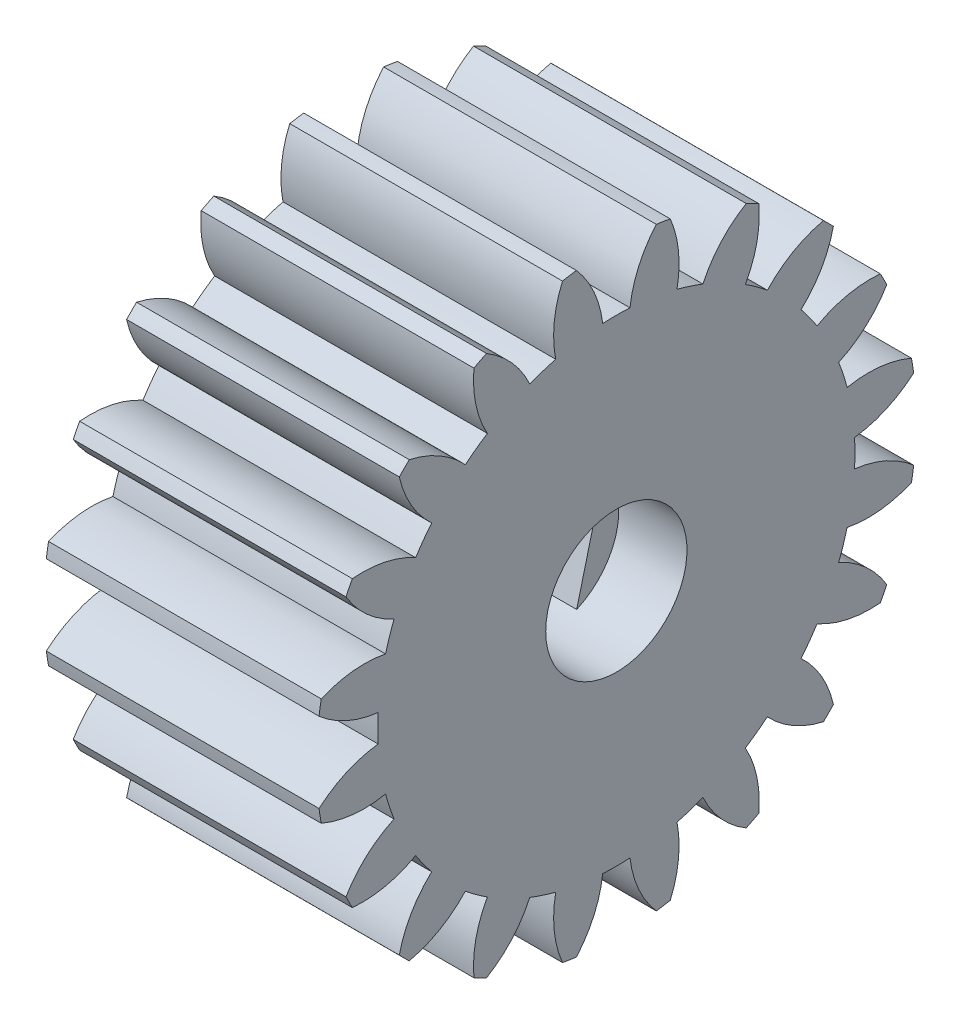
from build123d import *

# Parameters (mm, degrees)
SKETCH1_W           = 10
SKETCH1_H           = 11
CUT_EXTRUDE1_DEPTH  = 11
CUT_EXTRUDE2_DEPTH  = 11
CUT_EXTRUDE3_DEPTH  = 11
CUT_EXTRUDE4_DEPTH  = 11
CUT_EXTRUDE5_DEPTH  = 11
CUT_EXTRUDE6_DEPTH  = 11
CUT_EXTRUDE7_DEPTH  = 11
CUT_EXTRUDE8_DEPTH  = 11
CUT_EXTRUDE9_DEPTH  = 11
CUT_EXTRUDE10_DEPTH = 11
CUT_EXTRUDE11_DEPTH = 11
CUT_EXTRUDE12_DEPTH = 11
CUT_EXTRUDE13_DEPTH = 11
CUT_EXTRUDE14_DEPTH = 11
CUT_EXTRUDE15_DEPTH = 11
CUT_EXTRUDE16_DEPTH = 11
CUT_EXTRUDE17_DEPTH = 11
CUT_EXTRUDE18_DEPTH = 11
CUT_EXTRUDE19_DEPTH = 11
CUT_EXTRUDE20_DEPTH = 11
HOLE1_D             = 5.18
HOLE1_DEPTH         = 10
BOSS_EXTRUDE1_DEPTH = 7.5
BOSS_EXTRUDE2_DEPTH = 7.5


with BuildPart() as part:
    # Sketch1 → Revolve1 (revolve)
    with BuildSketch(Plane(origin=(0, 0, 0), x_dir=(-1, 0, 0), z_dir=(0, 0, -1))):
        with Locations((-5, 5.5)):
            Rectangle(SKETCH1_W, SKETCH1_H)
    revolve(axis=Axis((10, 0, 0), (-1, 0, 0)))

    # Sketch2 → Cut-Extrude1 (cut, through all)
    with BuildSketch(Plane.ZY):
        with BuildLine():
            ThreePointArc((10.821127601, -1.975651141), (9.66022001, -2.278635697), (8.461683425, -2.223716399))
            ThreePointArc((8.461683425, -2.223716399), (8.320793461, -2.703589684), (8.152713396, -3.174628369))
            ThreePointArc((8.152713396, -3.174628369), (9.154630615, -3.834679853), (9.915734733, -4.762163869))
            ThreePointArc((9.915734733, -4.762163869), (10.461621679, -3.399186938), (10.821127601, -1.975651141))
        make_face()
    extrude(amount=-CUT_EXTRUDE1_DEPTH, mode=Mode.SUBTRACT)

    # Sketch3 → Cut-Extrude2 (cut, through all)
    with BuildSketch(Plane.ZY):
        with BuildLine():
            ThreePointArc((9.680994141, -5.222868219), (8.483278035, -5.15228348), (7.360373002, -4.729683951))
            ThreePointArc((7.360373002, -4.729683951), (7.078089684, -5.142533172), (6.772677084, -5.538577987))
            ThreePointArc((6.772677084, -5.538577987), (7.521589858, -6.4759337), (7.958834566, -7.593217523))
            ThreePointArc((7.958834566, -7.593217523), (8.899186938, -6.465637775), (9.680994141, -5.222868219))
        make_face()
    extrude(amount=-CUT_EXTRUDE2_DEPTH, mode=Mode.SUBTRACT)

    # Sketch4 → Cut-Extrude3 (cut, through all)
    with BuildSketch(Plane.ZY):
        with BuildLine():
            ThreePointArc((5.222868219, -9.680994141), (6.465637775, -8.899186938), (7.593217523, -7.958834566))
            ThreePointArc((7.593217523, -7.958834566), (6.4759337, -7.521589858), (5.538577987, -6.772677084))
            ThreePointArc((5.538577987, -6.772677084), (5.142533172, -7.078089684), (4.729683951, -7.360373002))
            ThreePointArc((4.729683951, -7.360373002), (5.15228348, -8.483278035), (5.222868219, -9.680994141))
        make_face()
    extrude(amount=-CUT_EXTRUDE3_DEPTH, mode=Mode.SUBTRACT)

    # Sketch5 → Cut-Extrude4 (cut, through all)
    with BuildSketch(Plane.ZY):
        with BuildLine():
            ThreePointArc((1.975651141, -10.821127601), (3.399186938, -10.461621679), (4.762163869, -9.915734733))
            ThreePointArc((4.762163869, -9.915734733), (3.834679853, -9.154630615), (3.174628369, -8.152713396))
            ThreePointArc((3.174628369, -8.152713396), (2.703589684, -8.320793461), (2.223716399, -8.461683425))
            ThreePointArc((2.223716399, -8.461683425), (2.278635697, -9.66022001), (1.975651141, -10.821127601))
        make_face()
    extrude(amount=-CUT_EXTRUDE4_DEPTH, mode=Mode.SUBTRACT)

    # Sketch6 → Cut-Extrude5 (cut, through all)
    with BuildSketch(Plane.ZY):
        with BuildLine():
            ThreePointArc((1.464956435, -10.902013697), (0.818060825, -9.891552344), (0.499924007, -8.734705318))
            ThreePointArc((0.499924007, -8.734705318), (0, -8.749), (-0.499924007, -8.734705318))
            ThreePointArc((-0.499924007, -8.734705318), (-0.818060825, -9.891552344), (-1.464956435, -10.902013697))
            ThreePointArc((-1.464956435, -10.902013697), (0, -11), (1.464956435, -10.902013697))
        make_face()
    extrude(amount=-CUT_EXTRUDE5_DEPTH, mode=Mode.SUBTRACT)

    # Sketch7 → Cut-Extrude6 (cut, through all)
    with BuildSketch(Plane.ZY):
        with BuildLine():
            ThreePointArc((-1.975651141, -10.821127601), (-2.278635697, -9.66022001), (-2.223716399, -8.461683425))
            ThreePointArc((-2.223716399, -8.461683425), (-2.703589684, -8.320793461), (-3.174628369, -8.152713396))
            ThreePointArc((-3.174628369, -8.152713396), (-3.834679853, -9.154630615), (-4.762163869, -9.915734733))
            ThreePointArc((-4.762163869, -9.915734733), (-3.399186938, -10.461621679), (-1.975651141, -10.821127601))
        make_face()
    extrude(amount=-CUT_EXTRUDE6_DEPTH, mode=Mode.SUBTRACT)

    # Sketch8 → Cut-Extrude7 (cut, through all)
    with BuildSketch(Plane.ZY):
        with BuildLine():
            ThreePointArc((-5.222868219, -9.680994141), (-5.15228348, -8.483278035), (-4.729683951, -7.360373002))
            ThreePointArc((-4.729683951, -7.360373002), (-5.142533172, -7.078089684), (-5.538577987, -6.772677084))
            ThreePointArc((-5.538577987, -6.772677084), (-6.4759337, -7.521589858), (-7.593217523, -7.958834566))
            ThreePointArc((-7.593217523, -7.958834566), (-6.465637775, -8.899186938), (-5.222868219, -9.680994141))
        make_face()
    extrude(amount=-CUT_EXTRUDE7_DEPTH, mode=Mode.SUBTRACT)

    # Sketch9 → Cut-Extrude8 (cut, through all)
    with BuildSketch(Plane.ZY):
        with BuildLine():
            ThreePointArc((-7.958834566, -7.593217523), (-7.521589858, -6.4759337), (-6.772677084, -5.538577987))
            ThreePointArc((-6.772677084, -5.538577987), (-7.078089684, -5.142533172), (-7.360373002, -4.729683951))
            ThreePointArc((-7.360373002, -4.729683951), (-8.483278035, -5.15228348), (-9.680994141, -5.222868219))
            ThreePointArc((-9.680994141, -5.222868219), (-8.899186938, -6.465637775), (-7.958834566, -7.593217523))
        make_face()
    extrude(amount=-CUT_EXTRUDE8_DEPTH, mode=Mode.SUBTRACT)

    # Sketch10 → Cut-Extrude9 (cut, through all)
    with BuildSketch(Plane.ZY):
        with BuildLine():
            ThreePointArc((-9.915734733, -4.762163869), (-9.154630615, -3.834679853), (-8.152713396, -3.174628369))
            ThreePointArc((-8.152713396, -3.174628369), (-8.320793461, -2.703589684), (-8.461683425, -2.223716399))
            ThreePointArc((-8.461683425, -2.223716399), (-9.66022001, -2.278635697), (-10.821127601, -1.975651141))
            ThreePointArc((-10.821127601, -1.975651141), (-10.461621679, -3.399186938), (-9.915734733, -4.762163869))
        make_face()
    extrude(amount=-CUT_EXTRUDE9_DEPTH, mode=Mode.SUBTRACT)

    # Sketch11 → Cut-Extrude10 (cut, through all)
    with BuildSketch(Plane.ZY):
        with BuildLine():
            ThreePointArc((-10.902013697, -1.464956435), (-9.891552344, -0.818060825), (-8.734705318, -0.499924007))
            ThreePointArc((-8.734705318, -0.499924007), (-8.749, 0), (-8.734705318, 0.499924007))
            ThreePointArc((-8.734705318, 0.499924007), (-9.891552344, 0.818060825), (-10.902013697, 1.464956435))
            ThreePointArc((-10.902013697, 1.464956435), (-11, 0), (-10.902013697, -1.464956435))
        make_face()
    extrude(amount=-CUT_EXTRUDE10_DEPTH, mode=Mode.SUBTRACT)

    # Sketch12 → Cut-Extrude11 (cut, through all)
    with BuildSketch(Plane.ZY):
        with BuildLine():
            ThreePointArc((-10.821127601, 1.975651141), (-9.66022001, 2.278635697), (-8.461683425, 2.223716399))
            ThreePointArc((-8.461683425, 2.223716399), (-8.320793461, 2.703589684), (-8.152713396, 3.174628369))
            ThreePointArc((-8.152713396, 3.174628369), (-9.154630615, 3.834679853), (-9.915734733, 4.762163869))
            ThreePointArc((-9.915734733, 4.762163869), (-10.461621679, 3.399186938), (-10.821127601, 1.975651141))
        make_face()
    extrude(amount=-CUT_EXTRUDE11_DEPTH, mode=Mode.SUBTRACT)

    # Sketch13 → Cut-Extrude12 (cut, through all)
    with BuildSketch(Plane.ZY):
        with BuildLine():
            ThreePointArc((-9.680994141, 5.222868219), (-8.483278035, 5.15228348), (-7.360373002, 4.729683951))
            ThreePointArc((-7.360373002, 4.729683951), (-7.078089684, 5.142533172), (-6.772677084, 5.538577987))
            ThreePointArc((-6.772677084, 5.538577987), (-7.521589858, 6.4759337), (-7.958834566, 7.593217523))
            ThreePointArc((-7.958834566, 7.593217523), (-8.899186938, 6.465637775), (-9.680994141, 5.222868219))
        make_face()
    extrude(amount=-CUT_EXTRUDE12_DEPTH, mode=Mode.SUBTRACT)

    # Sketch14 → Cut-Extrude13 (cut, through all)
    with BuildSketch(Plane.ZY):
        with BuildLine():
            ThreePointArc((-7.593217523, 7.958834566), (-6.4759337, 7.521589858), (-5.538577987, 6.772677084))
            ThreePointArc((-5.538577987, 6.772677084), (-5.142533172, 7.078089684), (-4.729683951, 7.360373002))
            ThreePointArc((-4.729683951, 7.360373002), (-5.15228348, 8.483278035), (-5.222868219, 9.680994141))
            ThreePointArc((-5.222868219, 9.680994141), (-6.465637775, 8.899186938), (-7.593217523, 7.958834566))
        make_face()
    extrude(amount=-CUT_EXTRUDE13_DEPTH, mode=Mode.SUBTRACT)

    # Sketch15 → Cut-Extrude14 (cut, through all)
    with BuildSketch(Plane.ZY):
        with BuildLine():
            ThreePointArc((-4.762163869, 9.915734733), (-3.834679853, 9.154630615), (-3.174628369, 8.152713396))
            ThreePointArc((-3.174628369, 8.152713396), (-2.703589684, 8.320793461), (-2.223716399, 8.461683425))
            ThreePointArc((-2.223716399, 8.461683425), (-2.278635697, 9.66022001), (-1.975651141, 10.821127601))
            ThreePointArc((-1.975651141, 10.821127601), (-3.399186938, 10.461621679), (-4.762163869, 9.915734733))
        make_face()
    extrude(amount=-CUT_EXTRUDE14_DEPTH, mode=Mode.SUBTRACT)

    # Sketch16 → Cut-Extrude15 (cut, through all)
    with BuildSketch(Plane.ZY):
        with BuildLine():
            ThreePointArc((-1.464956435, 10.902013697), (-0.818060825, 9.891552344), (-0.499924007, 8.734705318))
            ThreePointArc((-0.499924007, 8.734705318), (0, 8.749), (0.499924007, 8.734705318))
            ThreePointArc((0.499924007, 8.734705318), (0.818060825, 9.891552344), (1.464956435, 10.902013697))
            ThreePointArc((1.464956435, 10.902013697), (0, 11), (-1.464956435, 10.902013697))
        make_face()
    extrude(amount=-CUT_EXTRUDE15_DEPTH, mode=Mode.SUBTRACT)

    # Sketch17 → Cut-Extrude16 (cut, through all)
    with BuildSketch(Plane.ZY):
        with BuildLine():
            ThreePointArc((1.975651141, 10.821127601), (2.278635697, 9.66022001), (2.223716399, 8.461683425))
            ThreePointArc((2.223716399, 8.461683425), (2.703589684, 8.320793461), (3.174628369, 8.152713396))
            ThreePointArc((3.174628369, 8.152713396), (3.834679853, 9.154630615), (4.762163869, 9.915734733))
            ThreePointArc((4.762163869, 9.915734733), (3.399186938, 10.461621679), (1.975651141, 10.821127601))
        make_face()
    extrude(amount=-CUT_EXTRUDE16_DEPTH, mode=Mode.SUBTRACT)

    # Sketch18 → Cut-Extrude17 (cut, through all)
    with BuildSketch(Plane.ZY):
        with BuildLine():
            ThreePointArc((5.222868219, 9.680994141), (5.15228348, 8.483278035), (4.729683951, 7.360373002))
            ThreePointArc((4.729683951, 7.360373002), (5.142533172, 7.078089684), (5.538577987, 6.772677084))
            ThreePointArc((5.538577987, 6.772677084), (6.4759337, 7.521589858), (7.593217523, 7.958834566))
            ThreePointArc((7.593217523, 7.958834566), (6.465637775, 8.899186938), (5.222868219, 9.680994141))
        make_face()
    extrude(amount=-CUT_EXTRUDE17_DEPTH, mode=Mode.SUBTRACT)

    # Sketch19 → Cut-Extrude18 (cut, through all)
    with BuildSketch(Plane.ZY):
        with BuildLine():
            ThreePointArc((7.958834566, 7.593217523), (7.521589858, 6.4759337), (6.772677084, 5.538577987))
            ThreePointArc((6.772677084, 5.538577987), (7.078089684, 5.142533172), (7.360373002, 4.729683951))
            ThreePointArc((7.360373002, 4.729683951), (8.483278035, 5.15228348), (9.680994141, 5.222868219))
            ThreePointArc((9.680994141, 5.222868219), (8.899186938, 6.465637775), (7.958834566, 7.593217523))
        make_face()
    extrude(amount=-CUT_EXTRUDE18_DEPTH, mode=Mode.SUBTRACT)

    # Sketch20 → Cut-Extrude19 (cut, through all)
    with BuildSketch(Plane.ZY):
        with BuildLine():
            ThreePointArc((9.915734733, 4.762163869), (9.154630615, 3.834679853), (8.152713396, 3.174628369))
            ThreePointArc((8.152713396, 3.174628369), (8.320793461, 2.703589684), (8.461683425, 2.223716399))
            ThreePointArc((8.461683425, 2.223716399), (9.66022001, 2.278635697), (10.821127601, 1.975651141))
            ThreePointArc((10.821127601, 1.975651141), (10.461621679, 3.399186938), (9.915734733, 4.762163869))
        make_face()
    extrude(amount=-CUT_EXTRUDE19_DEPTH, mode=Mode.SUBTRACT)

    # Sketch21 → Cut-Extrude20 (cut, through all)
    with BuildSketch(Plane.ZY):
        with BuildLine():
            ThreePointArc((10.902013697, 1.464956435), (9.891552344, 0.818060825), (8.734705318, 0.499924007))
            ThreePointArc((8.734705318, 0.499924007), (8.749, 0), (8.734705318, -0.499924007))
            ThreePointArc((8.734705318, -0.499924007), (9.891552344, -0.818060825), (10.902013697, -1.464956435))
            ThreePointArc((10.902013697, -1.464956435), (11, 0), (10.902013697, 1.464956435))
        make_face()
    extrude(amount=-CUT_EXTRUDE20_DEPTH, mode=Mode.SUBTRACT)

    # Hole1
    with Locations(Plane.ZY):
        with Locations((0, 0)):
            Hole(HOLE1_D / 2, depth=HOLE1_DEPTH)

    # Sketch24 → Boss-Extrude1 (add)
    with BuildSketch(Plane(origin=(0, 0, 0), x_dir=(0, -1, 0), z_dir=(-1, 0, 0))):
        with BuildLine():
            Line((-2.369432427, 1.045891951), (1.577107549, 2.054466301))
            ThreePointArc((1.577107549, 2.054466301), (-0.641287949, 2.50935246), (-2.369432427, 1.045891951))
        make_face()
    extrude(amount=-BOSS_EXTRUDE1_DEPTH)

    # Sketch25 → Boss-Extrude2 (add)
    with BuildSketch(Plane(origin=(0, 0, 0), x_dir=(0, -1, 0), z_dir=(-1, 0, 0))):
        with BuildLine():
            Line((2.369432427, -1.045891951), (-1.577107549, -2.054466301))
            ThreePointArc((-1.577107549, -2.054466301), (0.641287949, -2.50935246), (2.369432427, -1.045891951))
        make_face()
    extrude(amount=-BOSS_EXTRUDE2_DEPTH)


solid = part.part
